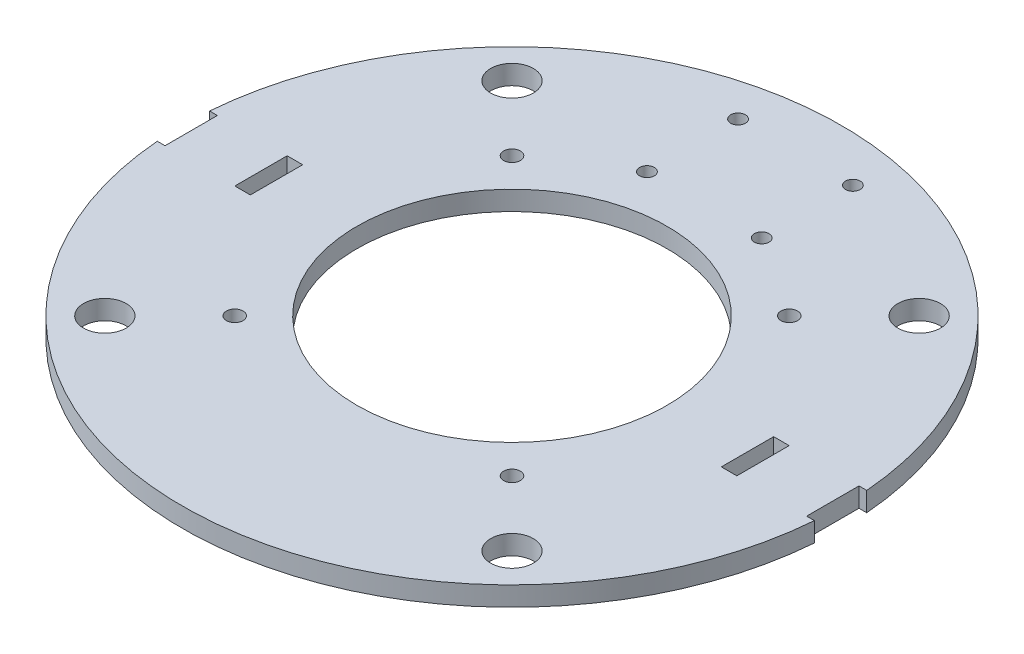
from build123d import *

# Parameters (mm, degrees)
SKETCH1_R               = 85
BASE_DEPTH              = 5
MAIN_WHEEL_SLOTS_REACH  = 7
SKETCH2_W               = 4
SKETCH2_H               = 13.5
F_3RD_WHEEL_HOLES_REACH = 7
SKETCH3_R               = 1.9
SKETCH6_R               = 2.15
FAN_SCREW_HOLES_DEPTH   = 6
SKETCH7_R               = 40
FAN_BLADE_HOLE_DEPTH    = 6
BOLT_HOLES_REACH        = 7
SKETCH8_R               = 5.5


with BuildPart() as part:
    # Sketch1 → Base (new body)
    with BuildSketch(Plane(origin=(0, 0, 0), x_dir=(1, 0, 0), z_dir=(0, 1, 0))):
        Circle(SKETCH1_R)
    extrude(amount=BASE_DEPTH)

    # Sketch2 → Main Wheel Slots (cut, up to next)
    with BuildSketch(Plane(origin=(0, 5, 0), x_dir=(1, 0, 0), z_dir=(0, 1, 0)), mode=Mode.PRIVATE) as main_wheel_slots_sk1:
        with Locations((62.731561416, 0)):
            Rectangle(SKETCH2_W, SKETCH2_H)
    main_wheel_slots_tool1 = extrude(main_wheel_slots_sk1.sketch, amount=-MAIN_WHEEL_SLOTS_REACH, mode=Mode.PRIVATE) & part.part
    add(main_wheel_slots_tool1.solids().sort_by_distance((62.731561, 5, 0))[0], mode=Mode.SUBTRACT)
    # Sketch2 → Main Wheel Slots (cut, up to next)
    with BuildSketch(Plane(origin=(0, 5, 0), x_dir=(1, 0, 0), z_dir=(0, 1, 0)), mode=Mode.PRIVATE) as main_wheel_slots_sk2:
        with BuildLine():
            ThreePointArc((85, 0), (84.932863841, 3.377667808), (84.731561416, 6.75))
            Line((84.731561416, 6.75), (82.731561416, 6.75))
            Line((82.731561416, 6.75), (82.731561416, -6.75))
            Line((82.731561416, -6.75), (84.731561416, -6.75))
            ThreePointArc((84.731561416, -6.75), (84.932863841, -3.377667808), (85, 0))
        make_face()
    main_wheel_slots_tool2 = extrude(main_wheel_slots_sk2.sketch, amount=-MAIN_WHEEL_SLOTS_REACH, mode=Mode.PRIVATE) & part.part
    add(main_wheel_slots_tool2.solids().sort_by_distance((83.822538, 5, 0))[0], mode=Mode.SUBTRACT)
    # Sketch2 → Main Wheel Slots (cut, up to next)
    with BuildSketch(Plane(origin=(0, 5, 0), x_dir=(1, 0, 0), z_dir=(0, 1, 0)), mode=Mode.PRIVATE) as main_wheel_slots_sk3:
        with BuildLine():
            Line((-82.731561416, 6.75), (-84.731561416, 6.75))
            ThreePointArc((-84.731561416, 6.75), (-85, 0), (-84.731561416, -6.75))
            Line((-84.731561416, -6.75), (-82.731561416, -6.75))
            Line((-82.731561416, -6.75), (-82.731561416, 6.75))
        make_face()
    main_wheel_slots_tool3 = extrude(main_wheel_slots_sk3.sketch, amount=-MAIN_WHEEL_SLOTS_REACH, mode=Mode.PRIVATE) & part.part
    add(main_wheel_slots_tool3.solids().sort_by_distance((-83.822538, 5, 0))[0], mode=Mode.SUBTRACT)
    # Sketch2 → Main Wheel Slots (cut, up to next)
    with BuildSketch(Plane(origin=(0, 5, 0), x_dir=(1, 0, 0), z_dir=(0, 1, 0)), mode=Mode.PRIVATE) as main_wheel_slots_sk4:
        with Locations((-62.731561416, 0)):
            Rectangle(SKETCH2_W, SKETCH2_H)
    main_wheel_slots_tool4 = extrude(main_wheel_slots_sk4.sketch, amount=-MAIN_WHEEL_SLOTS_REACH, mode=Mode.PRIVATE) & part.part
    add(main_wheel_slots_tool4.solids().sort_by_distance((-62.731561, 5, 0))[0], mode=Mode.SUBTRACT)

    # Sketch3 → 3rd Wheel Holes (cut, up to next)
    with BuildSketch(Plane(origin=(0, 5, 0), x_dir=(1, 0, 0), z_dir=(0, 1, 0)), mode=Mode.PRIVATE) as f_3rd_wheel_holes_sk1:
        with Locations((14.8, 73.1)):
            Circle(SKETCH3_R)
    f_3rd_wheel_holes_tool1 = extrude(f_3rd_wheel_holes_sk1.sketch, amount=-F_3RD_WHEEL_HOLES_REACH, mode=Mode.PRIVATE) & part.part
    add(f_3rd_wheel_holes_tool1.solids().sort_by_distance((14.8, 5, -73.1))[0], mode=Mode.SUBTRACT)
    # Sketch3 → 3rd Wheel Holes (cut, up to next)
    with BuildSketch(Plane(origin=(0, 5, 0), x_dir=(1, 0, 0), z_dir=(0, 1, 0)), mode=Mode.PRIVATE) as f_3rd_wheel_holes_sk2:
        with Locations((14.8, 49.6)):
            Circle(SKETCH3_R)
    f_3rd_wheel_holes_tool2 = extrude(f_3rd_wheel_holes_sk2.sketch, amount=-F_3RD_WHEEL_HOLES_REACH, mode=Mode.PRIVATE) & part.part
    add(f_3rd_wheel_holes_tool2.solids().sort_by_distance((14.8, 5, -49.6))[0], mode=Mode.SUBTRACT)
    # Sketch3 → 3rd Wheel Holes (cut, up to next)
    with BuildSketch(Plane(origin=(0, 5, 0), x_dir=(1, 0, 0), z_dir=(0, 1, 0)), mode=Mode.PRIVATE) as f_3rd_wheel_holes_sk3:
        with Locations((-14.8, 49.6)):
            Circle(SKETCH3_R)
    f_3rd_wheel_holes_tool3 = extrude(f_3rd_wheel_holes_sk3.sketch, amount=-F_3RD_WHEEL_HOLES_REACH, mode=Mode.PRIVATE) & part.part
    add(f_3rd_wheel_holes_tool3.solids().sort_by_distance((-14.8, 5, -49.6))[0], mode=Mode.SUBTRACT)
    # Sketch3 → 3rd Wheel Holes (cut, up to next)
    with BuildSketch(Plane(origin=(0, 5, 0), x_dir=(1, 0, 0), z_dir=(0, 1, 0)), mode=Mode.PRIVATE) as f_3rd_wheel_holes_sk4:
        with Locations((-14.8, 73.1)):
            Circle(SKETCH3_R)
    f_3rd_wheel_holes_tool4 = extrude(f_3rd_wheel_holes_sk4.sketch, amount=-F_3RD_WHEEL_HOLES_REACH, mode=Mode.PRIVATE) & part.part
    add(f_3rd_wheel_holes_tool4.solids().sort_by_distance((-14.8, 5, -73.1))[0], mode=Mode.SUBTRACT)

    # Sketch6 → Fan Screw Holes (cut)
    with BuildSketch(Plane(origin=(0, 5, 0), x_dir=(1, 0, 0), z_dir=(0, 1, 0))):
        with Locations((35.75, 35.75)):
            Circle(SKETCH6_R)
        with Locations((-35.75, 35.75)):
            Circle(SKETCH6_R)
        with Locations((35.75, -35.75)):
            Circle(SKETCH6_R)
        with Locations((-35.75, -35.75)):
            Circle(SKETCH6_R)
    extrude(amount=-FAN_SCREW_HOLES_DEPTH, mode=Mode.SUBTRACT)

    # Sketch7 → Fan Blade Hole (cut)
    with BuildSketch(Plane(origin=(0, 5, 0), x_dir=(1, 0, 0), z_dir=(0, 1, 0))):
        Circle(SKETCH7_R)
    extrude(amount=-FAN_BLADE_HOLE_DEPTH, mode=Mode.SUBTRACT)

    # Sketch8 → Bolt Holes (cut, up to next)
    with BuildSketch(Plane(origin=(0, 5, 0), x_dir=(1, 0, 0), z_dir=(0, 1, 0)), mode=Mode.PRIVATE) as bolt_holes_sk1:
        with Locations((52.5, 52.5)):
            Circle(SKETCH8_R)
    bolt_holes_tool1 = extrude(bolt_holes_sk1.sketch, amount=-BOLT_HOLES_REACH, mode=Mode.PRIVATE) & part.part
    add(bolt_holes_tool1.solids().sort_by_distance((52.5, 5, -52.5))[0], mode=Mode.SUBTRACT)
    # Sketch8 → Bolt Holes (cut, up to next)
    with BuildSketch(Plane(origin=(0, 5, 0), x_dir=(1, 0, 0), z_dir=(0, 1, 0)), mode=Mode.PRIVATE) as bolt_holes_sk2:
        with Locations((-52.5, 52.5)):
            Circle(SKETCH8_R)
    bolt_holes_tool2 = extrude(bolt_holes_sk2.sketch, amount=-BOLT_HOLES_REACH, mode=Mode.PRIVATE) & part.part
    add(bolt_holes_tool2.solids().sort_by_distance((-52.5, 5, -52.5))[0], mode=Mode.SUBTRACT)
    # Sketch8 → Bolt Holes (cut, up to next)
    with BuildSketch(Plane(origin=(0, 5, 0), x_dir=(1, 0, 0), z_dir=(0, 1, 0)), mode=Mode.PRIVATE) as bolt_holes_sk3:
        with Locations((52.5, -52.5)):
            Circle(SKETCH8_R)
    bolt_holes_tool3 = extrude(bolt_holes_sk3.sketch, amount=-BOLT_HOLES_REACH, mode=Mode.PRIVATE) & part.part
    add(bolt_holes_tool3.solids().sort_by_distance((52.5, 5, 52.5))[0], mode=Mode.SUBTRACT)
    # Sketch8 → Bolt Holes (cut, up to next)
    with BuildSketch(Plane(origin=(0, 5, 0), x_dir=(1, 0, 0), z_dir=(0, 1, 0)), mode=Mode.PRIVATE) as bolt_holes_sk4:
        with Locations((-52.5, -52.5)):
            Circle(SKETCH8_R)
    bolt_holes_tool4 = extrude(bolt_holes_sk4.sketch, amount=-BOLT_HOLES_REACH, mode=Mode.PRIVATE) & part.part
    add(bolt_holes_tool4.solids().sort_by_distance((-52.5, 5, 52.5))[0], mode=Mode.SUBTRACT)


solid = part.part
